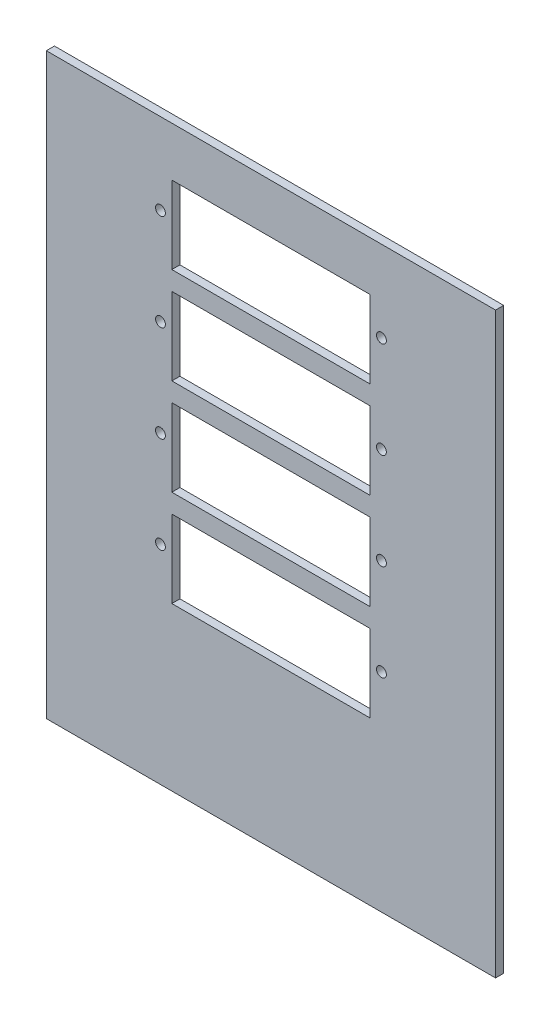
from build123d import *

# Parameters (mm, degrees)
ESQUISSE1_W                  = 233
ESQUISSE1_H                  = 300
BOSS_EXTRU_1_DEPTH           = 4.2
ESQUISSE2_R                  = 2.55
ESQUISSE2_W                  = 102.8
ESQUISSE2_H                  = 40.2
ENL_V_MAT_EXTRU_1_DEPTH      = 1
ENL_V_MAT_EXTRU_1_DEPTH_BACK = 5.2


with BuildPart() as part:
    # Esquisse1 → Boss.-Extru.1 (new body)
    with BuildSketch(Plane.XY):
        with Locations((-45.332061069, 23.536895674)):
            Rectangle(ESQUISSE1_W, ESQUISSE1_H)
    extrude(amount=BOSS_EXTRU_1_DEPTH)

    # Esquisse2 → Enlèv. mat.-Extru.1 (cut, two sides)
    with BuildSketch(Plane.XY.offset(4.2)) as enl_v_mat_extru_1_sk:
        with Locations((-102.632061069, 131.426895674)):
            Circle(ESQUISSE2_R)
        with Locations((11.967938931, 131.426895674)):
            Circle(ESQUISSE2_R)
        with Locations((-102.632061069, 81.426895674)):
            Circle(ESQUISSE2_R)
        with Locations((11.967938931, 81.426895674)):
            Circle(ESQUISSE2_R)
        with Locations((-102.632061069, 31.426895674)):
            Circle(ESQUISSE2_R)
        with Locations((11.967938931, 31.426895674)):
            Circle(ESQUISSE2_R)
        with Locations((-102.632061069, -18.573104326)):
            Circle(ESQUISSE2_R)
        with Locations((11.967938931, -18.573104326)):
            Circle(ESQUISSE2_R)
        with Locations((-45.332061069, -22.123104326)):
            Rectangle(ESQUISSE2_W, ESQUISSE2_H)
        with Locations((-45.332061069, 27.876895674)):
            Rectangle(ESQUISSE2_W, ESQUISSE2_H)
        with Locations((-45.332061069, 77.876895674)):
            Rectangle(ESQUISSE2_W, ESQUISSE2_H)
        with Locations((-45.332061069, 127.876895674)):
            Rectangle(ESQUISSE2_W, ESQUISSE2_H)
    extrude(amount=ENL_V_MAT_EXTRU_1_DEPTH, mode=Mode.SUBTRACT)
    extrude(enl_v_mat_extru_1_sk.sketch, amount=-ENL_V_MAT_EXTRU_1_DEPTH_BACK, mode=Mode.SUBTRACT)


solid = part.part
